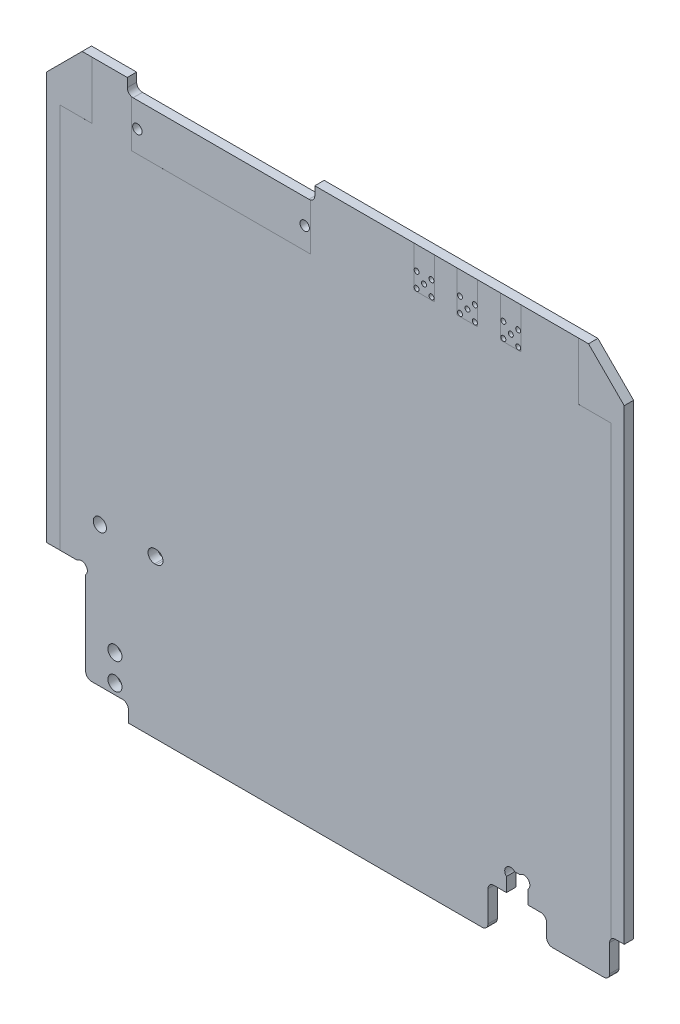
from build123d import *

# Parameters (mm, degrees)
SKETCH1_R           = 0.425
SKETCH1_R_2         = 0.8
BOSS_EXTRUDE1_DEPTH = 1.6
CUT_EXTRUDE1_DEPTH  = 0.0001
CUT_EXTRUDE2_DEPTH  = 0.0001
PARTFOOTPRINTS_W    = 30.48
PARTFOOTPRINTS_H    = 7.989227112
PARTFOOTPRINTS_W_2  = 3.5
PARTFOOTPRINTS_H_2  = 6.95
CUT_EXTRUDE3_DEPTH  = 0.0001
CUT_EXTRUDE4_DEPTH  = 2.6
SKETCH3_W           = 7.779754111
SKETCH3_H           = 5.155241991
CUT_EXTRUDE5_DEPTH  = 10
FILLET1_R           = 1
CUT_EXTRUDE6_DEPTH  = 2.6
FILLET2_R           = 1
SKETCH5_R           = 1.125
CUT_EXTRUDE7_DEPTH  = 2.6
SKETCH6_R           = 1.2
CUT_EXTRUDE8_DEPTH  = 2.6


with BuildPart() as part:
    # Sketch1 → Boss-Extrude1 (new body)
    with BuildSketch(Plane(origin=(0, 0, -0.0125), x_dir=(-1, 0, 0), z_dir=(0, 0, -1))):
        with BuildLine():
            Line((35.3, -50), (35.3, -48))
            ThreePointArc((35.3, -48), (35.592893219, -47.292893219), (36.3, -47))
            Line((36.3, -47), (45.8, -47))
            ThreePointArc((45.8, -47), (46.507106781, -46.707106781), (46.8, -46))
            Line((46.8, -46), (46.8, -41.4))
            ThreePointArc((46.8, -41.4), (47.092893219, -40.692893219), (47.8, -40.4))
            Line((47.8, -40.4), (49.3, -40.4))
            Line((49.3, -40.4), (49.3, 39.2))
            Line((49.3, 39.2), (43.2, 45.3))
            Line((43.2, 45.3), (35.500000002, 45.3))
            Line((35.500000002, 45.3), (35.500000002, 43.8))
            ThreePointArc((35.500000002, 43.8), (35.207106783, 43.092893219), (34.500000002, 42.8))
            Line((34.500000002, 42.8), (4.499999998, 42.8))
            ThreePointArc((4.499999998, 42.8), (3.792893217, 43.092893219), (3.499999998, 43.8))
            Line((3.499999998, 43.8), (3.499999998, 45.3))
            Line((3.499999998, 45.3), (-43.2, 45.3))
            Line((-43.2, 45.3), (-49.3, 39.2))
            Line((-49.3, 39.2), (-49.3, -40.4))
            Line((-49.3, -40.4), (-47.8, -40.4))
            ThreePointArc((-47.8, -40.4), (-47.092893219, -40.692893219), (-46.8, -41.4))
            Line((-46.8, -41.4), (-46.8, -46))
            ThreePointArc((-46.8, -46), (-46.507106781, -46.707106781), (-45.8, -47))
            Line((-45.8, -47), (-36.3, -47))
            ThreePointArc((-36.3, -47), (-35.592893219, -47.292893219), (-35.3, -48))
            Line((-35.3, -48), (-35.3, -50))
            Line((-35.3, -50), (35.3, -50))
        make_face()
        with Locations((-21.27, 41.37)):
            Circle(SKETCH1_R, mode=Mode.SUBTRACT)
        with Locations((-23.81, 41.37)):
            Circle(SKETCH1_R, mode=Mode.SUBTRACT)
        with Locations((-22.54, 40.1)):
            Circle(SKETCH1_R, mode=Mode.SUBTRACT)
        with Locations((-13.87, 41.37)):
            Circle(SKETCH1_R, mode=Mode.SUBTRACT)
        with Locations((-23.81, 38.83)):
            Circle(SKETCH1_R, mode=Mode.SUBTRACT)
        with Locations((-16.41, 41.37)):
            Circle(SKETCH1_R, mode=Mode.SUBTRACT)
        with Locations((-15.14, 40.1)):
            Circle(SKETCH1_R, mode=Mode.SUBTRACT)
        with Locations((-21.27, 38.83)):
            Circle(SKETCH1_R, mode=Mode.SUBTRACT)
        with Locations((-28.67, 41.37)):
            Circle(SKETCH1_R, mode=Mode.SUBTRACT)
        with Locations((-31.21, 41.37)):
            Circle(SKETCH1_R, mode=Mode.SUBTRACT)
        with Locations((-16.41, 38.83)):
            Circle(SKETCH1_R, mode=Mode.SUBTRACT)
        with Locations((-29.94, 40.1)):
            Circle(SKETCH1_R, mode=Mode.SUBTRACT)
        with Locations((-31.21, 38.83)):
            Circle(SKETCH1_R, mode=Mode.SUBTRACT)
        with Locations((-28.67, 38.83)):
            Circle(SKETCH1_R, mode=Mode.SUBTRACT)
        with Locations((33.775, 38.54)):
            Circle(SKETCH1_R_2, mode=Mode.SUBTRACT)
        with Locations((5.225, 38.54)):
            Circle(SKETCH1_R_2, mode=Mode.SUBTRACT)
        with Locations((-13.87, 38.83)):
            Circle(SKETCH1_R, mode=Mode.SUBTRACT)
    extrude(amount=-BOSS_EXTRUDE1_DEPTH)

    # thermalContacts_lower → Cut-Extrude1 (cut)
    with BuildSketch(Plane(origin=(0, 0, -0.0125), x_dir=(-1, 0, 0), z_dir=(0, 0, -1))):
        Polygon((47, 35.5), (47, -41.5), (59.827263463, -41.5), (59.827263463, 48.757689229), (41.5, 48.757689229), (41.5, 41.5), (41.5, 35.5), align=None)
        Polygon((-47, 35.5), (-47, -41.5), (-56.192158269, -41.5), (-56.192158269, 47), (-41.5, 47), (-41.5, 41.5), (-41.5, 35.5), align=None)
    extrude(amount=-CUT_EXTRUDE1_DEPTH, mode=Mode.SUBTRACT)

    # thermalContacts_upper → Cut-Extrude2 (cut)
    with BuildSketch(Plane.XY.offset(1.5875)):
        Polygon((-47, 35.5), (-47, -41.5), (-56.192158269, -41.5), (-56.192158269, 47), (-41.5, 47), (-41.5, 41.5), (-41.5, 35.5), align=None)
        Polygon((47, 35.5), (47, -41.5), (59.827263463, -41.5), (59.827263463, 47), (41.5, 47), (41.5, 41.5), (41.5, 35.5), align=None)
    extrude(amount=-CUT_EXTRUDE2_DEPTH, mode=Mode.SUBTRACT)

    # partFootprints → Cut-Extrude3 (cut)
    with BuildSketch(Plane.XY.offset(1.5875)):
        with Locations((-19.5, 38.834613556)):
            Rectangle(PARTFOOTPRINTS_W, PARTFOOTPRINTS_H)
        with Locations((15.14, 41.825)):
            Rectangle(PARTFOOTPRINTS_W_2, PARTFOOTPRINTS_H_2)
        with Locations((22.54, 41.825)):
            Rectangle(PARTFOOTPRINTS_W_2, PARTFOOTPRINTS_H_2)
        with Locations((29.94, 41.825)):
            Rectangle(PARTFOOTPRINTS_W_2, PARTFOOTPRINTS_H_2)
    extrude(amount=-CUT_EXTRUDE3_DEPTH, mode=Mode.SUBTRACT)

    # Sketch2 → Cut-Extrude4 (cut, through all)
    with BuildSketch(Plane.XY.offset(1.5875)):
        with BuildLine():
            Line((29.2, -42.8), (29.2, -40.414213562))
            ThreePointArc((29.2, -40.414213562), (29.2, -39), (30.614213562, -39))
            Line((30.614213562, -39), (31.485786438, -39))
            ThreePointArc((31.485786438, -39), (32.9, -39), (32.9, -40.414213562))
            Line((32.9, -40.414213562), (32.9, -42.8))
            Line((32.9, -42.8), (36.05, -42.8))
            Line((36.05, -42.8), (36.05, -50))
            Line((36.05, -50), (26.05, -50))
            Line((26.05, -50), (26.05, -42.8))
            Line((26.05, -42.8), (29.2, -42.8))
        make_face()
    extrude(amount=-CUT_EXTRUDE4_DEPTH, mode=Mode.SUBTRACT)

    # Sketch3 → Cut-Extrude5 (cut)
    with BuildSketch(Plane.XY.offset(1.5875)):
        with Locations((35.630924609, -49.577620995)):
            Rectangle(SKETCH3_W, SKETCH3_H)
    extrude(amount=-CUT_EXTRUDE5_DEPTH, mode=Mode.SUBTRACT)

    # Fillet1
    fillet1_edges = [part.edges().sort_by_distance(p)[0] for p in [
        (26.05, -50, 0.7875),
        (26.05, -42.8, 0.7875),
        (36.05, -42.8, 0.7875),
        (36.05, -47, 0.7875),
    ]]
    fillet(fillet1_edges, radius=FILLET1_R)

    # Sketch4 → Cut-Extrude6 (cut, through all)
    with BuildSketch(Plane.XY.offset(1.5875)):
        with BuildLine():
            Line((-51.38081647, -30.3), (-44.014213562, -30.3))
            ThreePointArc((-44.014213562, -30.3), (-42.6, -30.3), (-42.6, -31.714213562))
            Line((-42.6, -31.714213562), (-42.6, -47))
            Line((-42.6, -47), (-51.38081647, -47))
            Line((-51.38081647, -47), (-51.38081647, -30.3))
        make_face()
    extrude(amount=-CUT_EXTRUDE6_DEPTH, mode=Mode.SUBTRACT)

    # Fillet2
    fillet2_edges = [part.edges().sort_by_distance(p)[0] for p in [
        (-42.6, -47, 0.7875),
    ]]
    fillet(fillet2_edges, radius=FILLET2_R)

    # Sketch5 → Cut-Extrude7 (cut, through all)
    with BuildSketch(Plane.XY.offset(1.5875)):
        with Locations((-40.175, -23.1)):
            Circle(SKETCH5_R)
        with BuildLine():
            Line((-30.525, -24.225), (-30.825, -24.225))
            ThreePointArc((-30.825, -24.225), (-31.95, -23.1), (-30.825, -21.975))
            Line((-30.825, -21.975), (-30.525, -21.975))
            ThreePointArc((-30.525, -21.975), (-29.4, -23.1), (-30.525, -24.225))
        make_face()
    extrude(amount=-CUT_EXTRUDE7_DEPTH, mode=Mode.SUBTRACT)

    # Sketch6 → Cut-Extrude8 (cut, through all)
    with BuildSketch(Plane.XY.offset(1.5875)):
        with Locations((-37.6, -40.75)):
            Circle(SKETCH6_R)
        with Locations((-37.6, -45.25)):
            Circle(SKETCH6_R)
    extrude(amount=-CUT_EXTRUDE8_DEPTH, mode=Mode.SUBTRACT)


solid = part.part
